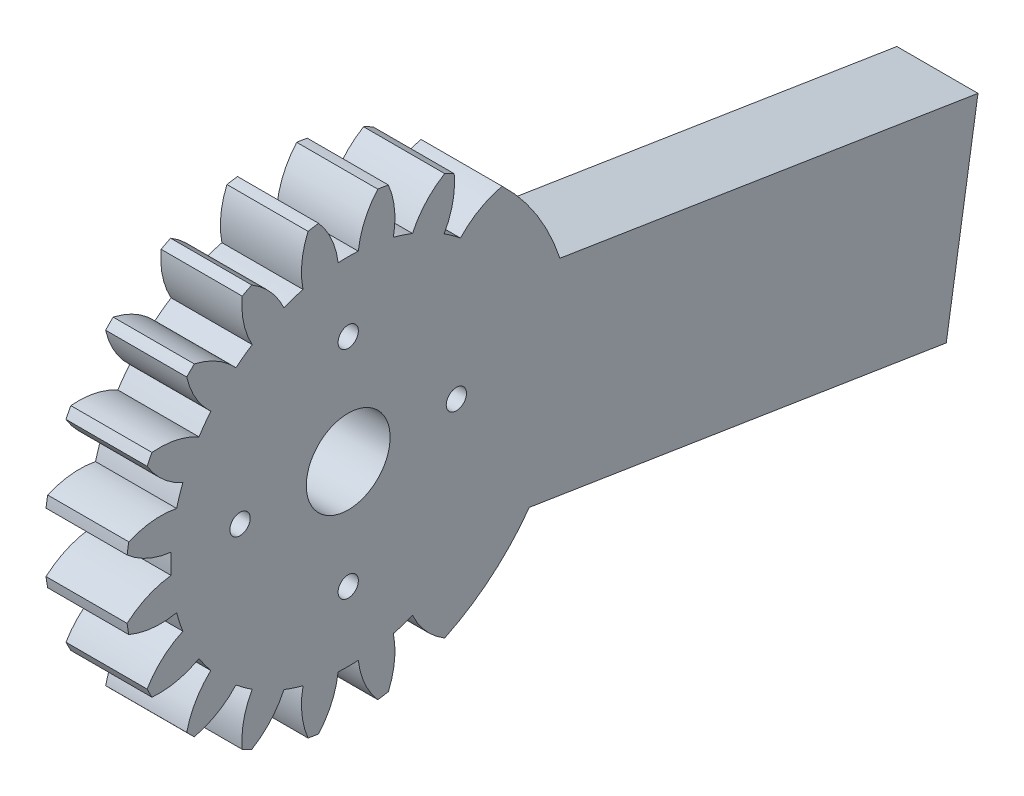
from build123d import *

# Parameters (mm, degrees)
BASPROSKE_W             = 6
BASPROSKE_H             = 16.5
TOOTHCUT_DEPTH          = 25.093567606
TEETHCUTS_COUNT         = 20
TEETHCUTS_ANGLE         = 342
BORSKE_R                = 3.1
BORE_DEPTH              = 50.0000508
BOSS_EXTRU_1_DEPTH      = 6
ESQUISSE3_R             = 0.75
ENL_V_MAT_EXTRU_1_DEPTH = 6


with BuildPart() as part:
    # BasProSke → Base-Revolve (revolve)
    with BuildSketch(Plane(origin=(0, 0, 0), x_dir=(1, 0, 0), z_dir=(0, 1, 0)), mode=Mode.PRIVATE) as base_revolve_sk:
        with Locations((3, 8.25)):
            Rectangle(BASPROSKE_W, BASPROSKE_H)
    revolve(base_revolve_sk.sketch.rotate(Axis((-10, 0, 0), (1, 0, 0)), 180), axis=Axis((-10, 0, 0), (1, 0, 0)))

    # TooCutSke → ToothCut (cut, through all)
    with BuildSketch(Plane(origin=(0, 0, 0), x_dir=(0, 0, -1), z_dir=(1, 0, 0))):
        with BuildLine():
            ThreePointArc((0.74381438, 13.102904875), (0, 13.124), (-0.74381438, 13.102904875))
            ThreePointArc((-0.74381438, 13.102904875), (-1.226473103, 14.852072512), (-2.209965745, 16.376962373))
            ThreePointArc((-2.209965745, 16.376962373), (0, 16.5254), (2.209965745, 16.376962373))
            ThreePointArc((2.209965745, 16.376962373), (1.226473103, 14.852072512), (0.74381438, 13.102904875))
        make_face()
    toothcut = extrude(amount=TOOTHCUT_DEPTH, mode=Mode.SUBTRACT)

    # TeethCuts: ToothCut ×20 about axis, 6 skipped
    teethcuts_axis = Axis((-10, 0, 0), (1, 0, 0))
    add([toothcut.rotate(teethcuts_axis, i * TEETHCUTS_ANGLE / (TEETHCUTS_COUNT - 1)) for i in range(1, TEETHCUTS_COUNT) if i not in (12, 13, 14, 15, 16, 17)], mode=Mode.SUBTRACT)

    # BorSke → Bore (cut, symmetric)
    with BuildSketch(Plane(origin=(0, 0, 0), x_dir=(0, 0, -1), z_dir=(1, 0, 0))):
        with Locations(Location((0, 0, 0), (0, 0, 180))):
            Circle(BORSKE_R)
    extrude(amount=BORE_DEPTH, both=True, mode=Mode.SUBTRACT)

    # Esquisse2 → Boss.-Extru.1 (add)
    with BuildSketch(Plane(origin=(6, 0, 0), x_dir=(0, 0, -1), z_dir=(1, 0, 0))):
        Polygon((10.44563255, 6.017449598), (8.099115574, -8.797875511), (44.238631957, -14.521812587), (46.585148932, 0.293512522), align=None)
    extrude(amount=-BOSS_EXTRU_1_DEPTH)

    # Esquisse3 → Enlèv. mat.-Extru.1 (cut)
    with BuildSketch(Plane.ZY):
        with Locations((8, 0)):
            Circle(ESQUISSE3_R)
        with Locations((-8, 0)):
            Circle(ESQUISSE3_R)
        with Locations((0, 8)):
            Circle(ESQUISSE3_R)
        with Locations((0, -8)):
            Circle(ESQUISSE3_R)
    extrude(amount=-ENL_V_MAT_EXTRU_1_DEPTH, mode=Mode.SUBTRACT)


solid = part.part
